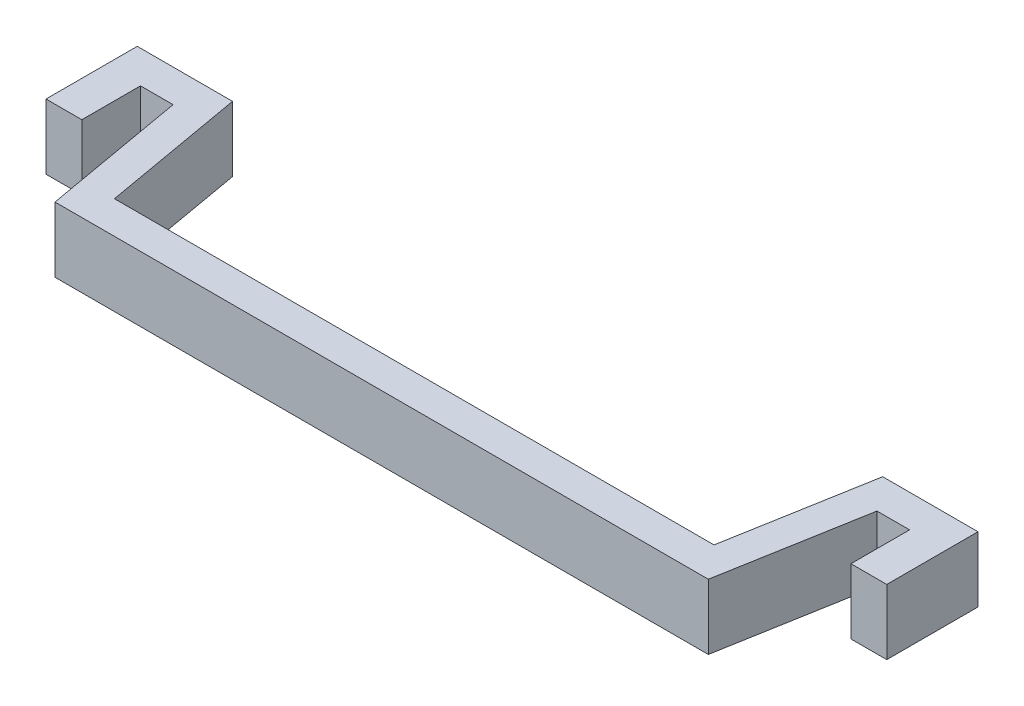
from build123d import *

# Parameters (mm, degrees)
BOSS_EXTRUDE1_DEPTH = 2.54


with BuildPart() as part:
    # Sketch1 → Boss-Extrude1 (new body)
    with BuildSketch(Plane(origin=(0, 0, 0), x_dir=(1, 0, 0), z_dir=(0, 1, 0))):
        Polygon((12.730684832, 0), (-12.730684832, 0), (-13.716, 5.588), (-14.986, 5.588), (-14.986, 3.302), (-16.383, 3.302), (-16.383, 6.858), (-12.669315168, 6.858), (-11.684, 1.27), (11.684, 1.27), (12.669315168, 6.858), (16.383, 6.858), (16.383, 3.302), (14.986, 3.302), (14.986, 5.588), (13.716, 5.588), align=None)
    extrude(amount=BOSS_EXTRUDE1_DEPTH)


solid = part.part
